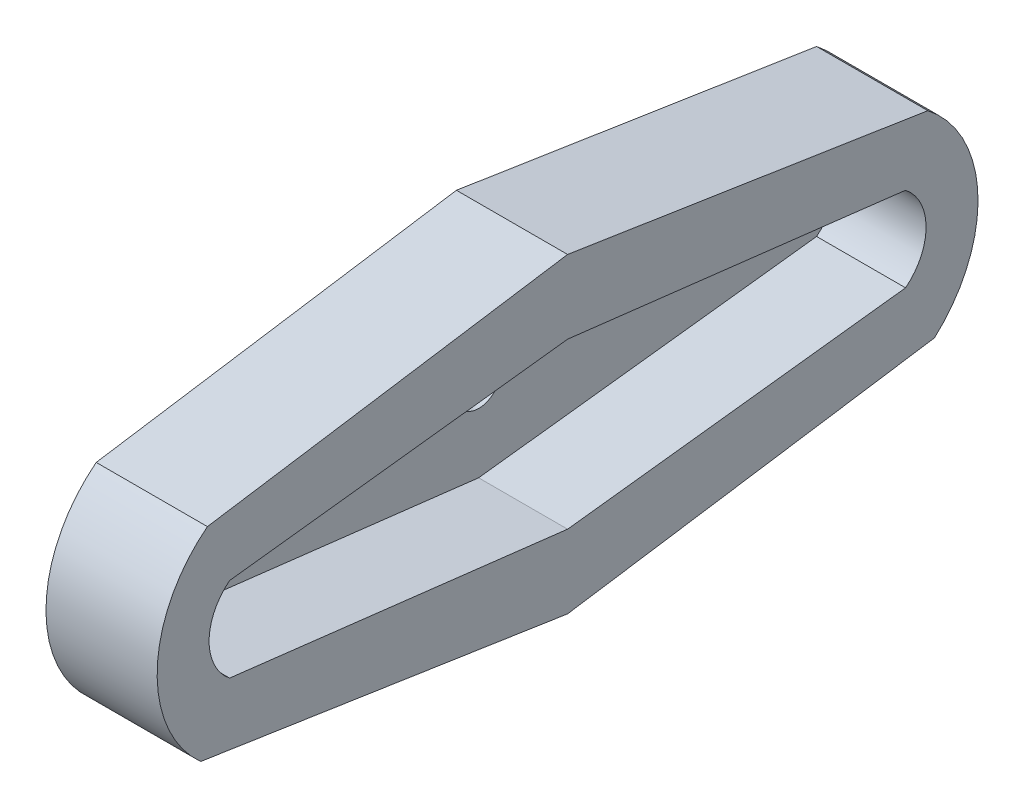
from build123d import *

# Parameters (mm, degrees)
BOSS_EXTRUDE1_DEPTH = 4
SKETCH2_R           = 1
BOSS_EXTRUDE2_DEPTH = 1


with BuildPart() as part:
    # Sketch1 → Boss-Extrude1 (new body)
    with BuildSketch(Plane(origin=(0, 0, 0), x_dir=(0, 0, -1), z_dir=(1, 0, 0))):
        with BuildLine():
            Line((0, 7), (-16.2, 4.5))
            ThreePointArc((-16.2, 4.5), (-18.456321812, 0.070210727), (-16.5, -4.5))
            Line((-16.5, -4.5), (0, -7))
            Line((0, -7), (16.5, -4.5))
            ThreePointArc((16.5, -4.5), (18.456321812, 0.070210727), (16.2, 4.5))
            Line((16.2, 4.5), (0, 7))
        make_face()
        with BuildLine():
            Line((0, 3.7), (-15.2, 1.9))
            ThreePointArc((-15.2, 1.9), (-16.123290742, 0), (-15.2, -1.9))
            Line((-15.2, -1.9), (0, -3.7))
            Line((0, -3.7), (15.2, -1.9))
            ThreePointArc((15.2, -1.9), (16.123290742, 0), (15.2, 1.9))
            Line((15.2, 1.9), (0, 3.7))
        make_face(mode=Mode.SUBTRACT)
    extrude(amount=BOSS_EXTRUDE1_DEPTH)

    # Sketch2 → Boss-Extrude2 (add)
    with BuildSketch(Plane(origin=(0, 0, 0), x_dir=(0, 0, -1), z_dir=(1, 0, 0))):
        with BuildLine():
            Line((0, 7), (-16.2, 4.5))
            ThreePointArc((-16.2, 4.5), (-18.456321812, 0.070210727), (-16.5, -4.5))
            Line((-16.5, -4.5), (0, -7))
            Line((0, -7), (16.5, -4.5))
            ThreePointArc((16.5, -4.5), (18.456321812, 0.070210727), (16.2, 4.5))
            Line((16.2, 4.5), (0, 7))
        make_face()
        Circle(SKETCH2_R, mode=Mode.SUBTRACT)
    extrude(amount=-BOSS_EXTRUDE2_DEPTH)


solid = part.part
